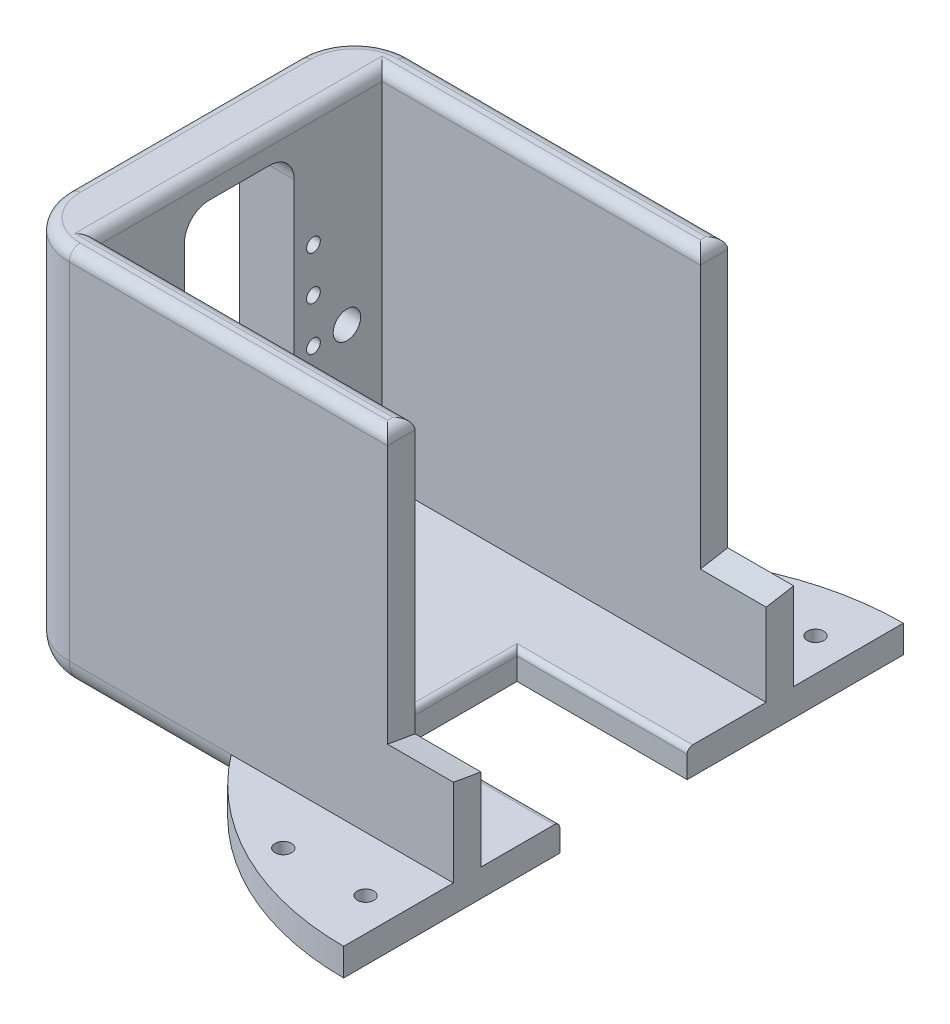
from build123d import *

# Parameters (mm, degrees)
BOSS_EXTRU_5_DEPTH       = 50
ESQUISSE5_R              = 2.15
ESQUISSE5_W              = 20
ESQUISSE5_H              = 31.8
ENL_V_MAT_EXTRU_1_DEPTH  = 10
BOSS_EXTRU_6_DEPTH       = 5
ESQUISSE11_R             = 2.5
ENL_V_MAT_EXTRU_9_DEPTH  = 5
CONG_1_R                 = 10
ENL_V_MAT_EXTRU_12_DEPTH = 12
ESQUISSE12_W             = 31
ESQUISSE12_H             = 23.2
ENL_V_MAT_EXTRU_13_DEPTH = 10
CONG_2_R                 = 1
ESQUISSE9_W              = 62
ESQUISSE9_H              = 34.999999956
ENL_V_MAT_EXTRU_14_DEPTH = 110.66312051
CONG_3_R                 = 5
CONG_4_R                 = 2
ESQUISSE13_R             = 1.5
ENL_V_MAT_EXTRU_15_DEPTH = 116.004347813
TROU_TARAUD_M31_D        = 2.5
TROU_TARAUD_M31_DEPTH    = 12.5
TROU_TARAUD_M31_TIP      = 0.751075774
ESQUISSE3D2_R            = 1.75
ENL_V_MAT_EXTRU_16_DEPTH = 8
ENL_V_MAT_EXTRU_17_DEPTH = 10


with BuildPart() as part:
    # Esquisse1 → Boss.-Extru.5 (new, symmetric)
    with BuildSketch(Plane(origin=(0, 0, 0), x_dir=(1, 0, 0), z_dir=(0, 1, 0))):
        Polygon((0, 31), (-40.496913463, 31), (-80, 31), (-80, -31), (-40.496913463, -31), (0, -31), (0, -26), (-40.496913463, -26), (-70, -26), (-70, 26), (-40.496913463, 26), (0, 26), align=None)
    extrude(amount=BOSS_EXTRU_5_DEPTH, both=True)

    # Esquisse5 → Enlèv. mat.-Extru.1 (cut)
    with BuildSketch(Plane(origin=(-70, 0, 0), x_dir=(0, 0, -1), z_dir=(1, 0, 0))):
        with BuildLine():
            Line((-10, -2), (10, -2))
            Line((10, -2), (10, 5.500000044))
            ThreePointArc((10, 5.500000044), (8.681980515, 8.68198056), (5.5, 10.000000044))
            Line((5.5, 10.000000044), (-5.499999911, 10.000000044))
            ThreePointArc((-5.499999911, 10.000000044), (-8.681980489, 8.681980534), (-10, 5.499999956))
            Line((-10, 5.499999956), (-10, -2))
        make_face()
        Circle(ESQUISSE5_R, mode=Mode.SUBTRACT)
        Circle(ESQUISSE5_R)
        with Locations((0, -17.9)):
            Rectangle(ESQUISSE5_W, ESQUISSE5_H)
        with BuildLine():
            ThreePointArc((2.15, 0), (-1.209582286, 1.77747312), (-0.788986692, -2))
            Line((-0.788986692, -2), (0.788986692, -2))
            ThreePointArc((0.788986692, -2), (1.77747312, -1.209582286), (2.15, 0))
        make_face()
        with BuildLine():
            Line((0.788986692, -2), (-0.788986692, -2))
            ThreePointArc((-0.788986692, -2), (0, -2.15), (0.788986692, -2))
        make_face()
    extrude(amount=-ENL_V_MAT_EXTRU_1_DEPTH, mode=Mode.SUBTRACT)

    # Esquisse8 → Boss.-Extru.6 (add)
    with BuildSketch(Plane(origin=(0, -50, 0), x_dir=(1, 0, 0), z_dir=(0, 1, 0))):
        with BuildLine():
            Line((0, -50.999999907), (0, 50.999999907))
            ThreePointArc((0, 50.999999907), (-22.584882388, 45.728136811), (-40.5, 31))
            Line((-40.5, 31), (-80, 31))
            Line((-80, 31), (-80, -31))
            Line((-80, -31), (-40.5, -31))
            ThreePointArc((-40.5, -31), (-22.584882388, -45.728136811), (0, -50.999999907))
        make_face()
    extrude(amount=-BOSS_EXTRU_6_DEPTH)

    # Esquisse11 → Enlèv. mat.-Extru.9 (cut)
    with BuildSketch(Plane(origin=(-70, 0, 0), x_dir=(0, 0, -1), z_dir=(1, 0, 0))):
        with Locations((-19.6, -22.213953616)):
            Circle(ESQUISSE11_R)
        with Locations((19.6, -22.213953616)):
            Circle(ESQUISSE11_R)
    extrude(amount=-ENL_V_MAT_EXTRU_9_DEPTH, mode=Mode.SUBTRACT)

    # Congé1
    cong_1_edges = [part.edges().sort_by_distance(p)[0] for p in [
        (-80, -2.5, 31),
        (-80, -2.5, -31),
    ]]
    fillet(cong_1_edges, radius=CONG_1_R)

    # Esquisse10 → Enlèv. mat.-Extru.12 (cut)
    with BuildSketch(Plane(origin=(0, 0, 0), x_dir=(0, 0, -1), z_dir=(1, 0, 0))):
        with BuildLine():
            Line((85.263165158, 65.69401727), (136.28713183, 33.486696785))
            ThreePointArc((136.28713183, 33.486696785), (0, -37), (-136.28713183, 33.486696785))
            Line((-136.28713183, 33.486696785), (-85.263165158, 65.69401727))
            ThreePointArc((-85.263165158, 65.69401727), (0, 23.205492896), (85.263165158, 65.69401727))
        make_face()
    extrude(amount=-ENL_V_MAT_EXTRU_12_DEPTH, mode=Mode.SUBTRACT)

    # Esquisse12 → Enlèv. mat.-Extru.13 (cut)
    with BuildSketch(Plane(origin=(0, -55, 0), x_dir=(-1, 0, 0), z_dir=(0, -1, 0))):
        with Locations((15.5, 0)):
            Rectangle(ESQUISSE12_W, ESQUISSE12_H)
    extrude(amount=-ENL_V_MAT_EXTRU_13_DEPTH, mode=Mode.SUBTRACT)

    # Congé2
    cong_2_edges = [part.edges().sort_by_distance(p)[0] for p in [
        (-15.5, -50, -11.6),
        (-31, -50, 0),
        (-15.5, -50, 11.6),
    ]]
    fillet(cong_2_edges, radius=CONG_2_R)

    # Esquisse9 → Enlèv. mat.-Extru.14 (cut, through all)
    with BuildSketch(Plane(origin=(0, 0, 0), x_dir=(0, 0, -1), z_dir=(1, 0, 0))):
        with Locations((0, 32.500000022)):
            Rectangle(ESQUISSE9_W, ESQUISSE9_H)
    extrude(amount=-ENL_V_MAT_EXTRU_14_DEPTH, mode=Mode.SUBTRACT)

    # Congé3
    cong_3_edges = [part.edges().sort_by_distance(p)[0] for p in [
        (-55.25, -55, 31),
        (-77.071067812, -55, 28.071067812),
        (-80, -55, 0),
        (-77.071067812, -55, -28.071067812),
        (-55.25, -55, -31),
    ]]
    fillet(cong_3_edges, radius=CONG_3_R)

    # Congé4
    cong_4_edges = [part.edges().sort_by_distance(p)[0] for p in [
        (-12, 15.000000044, 28.5),
        (-77.071067812, 15.000000044, 28.071067812),
        (-77.071067812, 15.000000044, -28.071067812),
        (-12, 15.000000044, -28.5),
        (-41, 15.000000044, 26),
        (-70, 15.000000044, 0),
        (-41, 15.000000044, 31),
        (-80, 15.000000044, 0),
        (-41, 15.000000044, -31),
        (-41, 15.000000044, -26),
    ]]
    fillet(cong_4_edges, radius=CONG_4_R)

    # Esquisse13 → Enlèv. mat.-Extru.15 (cut, through all)
    with BuildSketch(Plane(origin=(0, -50, 0), x_dir=(1, 0, 0), z_dir=(0, 1, 0))):
        with Locations(Location((-21, 40.999999953, 0), (0, 0, 270))):
            Circle(ESQUISSE13_R)
        with Locations(Location((-6, 40.999999953, 0), (0, 0, 270))):
            Circle(ESQUISSE13_R)
        with Locations(Location((-6, -40.999999953, 0), (0, 0, 90))):
            Circle(ESQUISSE13_R)
        with Locations(Location((-21, -40.999999953, 0), (0, 0, 90))):
            Circle(ESQUISSE13_R)
    extrude(amount=-ENL_V_MAT_EXTRU_15_DEPTH, mode=Mode.SUBTRACT)

    # Trou taraudé M31
    with Locations(Plane(origin=(-70, -6.5, 13.5), x_dir=(0, 0, 1), z_dir=(1, 0, 0))):
        with Locations((0, 0), (-27, 0), (-27, 8), (0, 8), (0, 16), (-27, 16), (-27, 24), (0, 24)):
            Hole(TROU_TARAUD_M31_D / 2, depth=TROU_TARAUD_M31_DEPTH)
            with Locations((0, 0, -(TROU_TARAUD_M31_DEPTH + TROU_TARAUD_M31_TIP / 2))):  # 118° drill point
                Cone(0, TROU_TARAUD_M31_D / 2, TROU_TARAUD_M31_TIP, mode=Mode.SUBTRACT)

    # Esquisse3D2 → Enlèv. mat.-Extru.16 (cut)
    with BuildSketch(Plane(origin=(-80, -6.5, 13.5), x_dir=(0, -0.6643638388299197, -0.7474093186836598), z_dir=(-1, 0, 0))):
        with Locations(Location((0, 0, 0), (0, 0, 318.366460663))):
            Circle(ESQUISSE3D2_R)
        with Locations(Location((5.314910711, 5.979274549, 0), (0, 0, 318.366460663))):
            Circle(ESQUISSE3D2_R)
        with Locations(Location((10.629821421, 11.958549099, 0), (0, 0, 318.366460663))):
            Circle(ESQUISSE3D2_R)
        with Locations(Location((20.180051604, -17.937823648, 0), (0, 0, 318.366460663))):
            Circle(ESQUISSE3D2_R)
        with Locations(Location((25.494962315, -11.958549099, 0), (0, 0, 318.366460663))):
            Circle(ESQUISSE3D2_R)
        with Locations(Location((30.809873026, -5.979274549, 0), (0, 0, 318.366460663))):
            Circle(ESQUISSE3D2_R)
        with Locations(Location((36.124783736, 0, 0), (0, 0, 318.366460663))):
            Circle(ESQUISSE3D2_R)
        with Locations(Location((15.944732132, 17.937823648, 0), (0, 0, 318.366460663))):
            Circle(ESQUISSE3D2_R)
    extrude(amount=-ENL_V_MAT_EXTRU_16_DEPTH, mode=Mode.SUBTRACT)

    # Esquisse3D3 → Enlèv. mat.-Extru.17 (cut)
    with BuildSketch(Plane(origin=(-80, -44, 6), x_dir=(0, -0.4472135954999578, -0.894427190999916), z_dir=(1, 0, 0))):
        Polygon((0, 0), (10.733126292, 5.366563146), (13.416407865, 0), (2.683281573, -5.366563146), align=None)
    extrude(amount=ENL_V_MAT_EXTRU_17_DEPTH, mode=Mode.SUBTRACT)


solid = part.part
